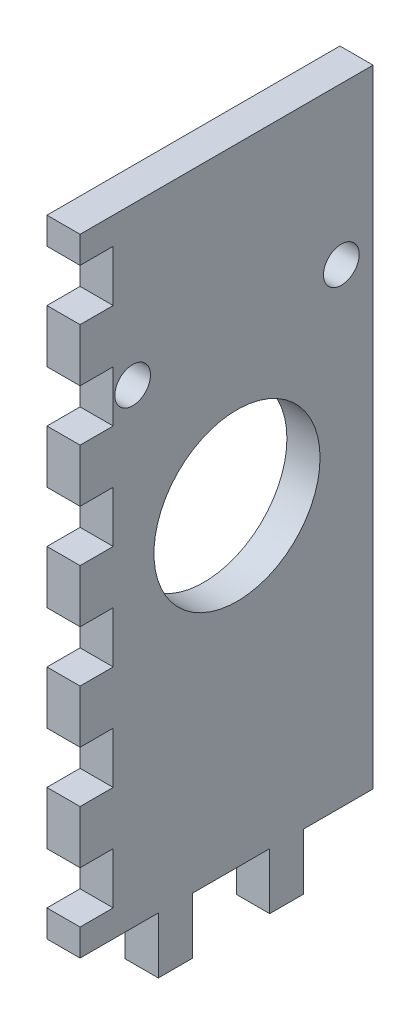
from build123d import *

# Parameters (mm, degrees)
SKETCH1_W           = 24.825
SKETCH1_H           = 3.175
SKETCH1_W_2         = 3.175
SKETCH1_H_2         = 24.825
BOSS_EXTRUDE1_DEPTH = 60
SKETCH2_W           = 3.125
SKETCH2_H           = 5.4
BOSS_EXTRUDE4_DEPTH = 3.175
SKETCH4_R           = 8
CUT_EXTRUDE1_DEPTH  = 3.175
SKETCH3_R           = 8
CUT_EXTRUDE2_DEPTH  = 3.175
SKETCH5_W           = 3.175
SKETCH5_H           = 5.4
BOSS_EXTRUDE5_DEPTH = 3.175
SKETCH6_R           = 1.75
CUT_EXTRUDE3_DEPTH  = 10
SKETCH7_R           = 1.75
CUT_EXTRUDE4_DEPTH  = 10
SKETCH9_W           = 3.175
SKETCH9_H           = 65.4
CUT_EXTRUDE5_DEPTH  = 24.825
SKETCH10_W          = 3.175
SKETCH10_H          = 5
CUT_EXTRUDE6_DEPTH  = 10
SKETCH11_R          = 7.95936
SKETCH11_R_2        = 1.70936
BOSS_EXTRUDE6_DEPTH = 3.175


with BuildPart() as part:
    # Sketch1 → Boss-Extrude1 (new body)
    with BuildSketch(Plane(origin=(0, 0, 0), x_dir=(1, 0, 0), z_dir=(0, 1, 0))):
        with Locations((-38.0875, 24.0875)):
            Rectangle(SKETCH1_W, SKETCH1_H)
        with Locations((-24.0875, 24.0875)):
            Rectangle(SKETCH1_W_2, SKETCH1_H)
        with Locations((-24.0875, 38.0875)):
            Rectangle(SKETCH1_W_2, SKETCH1_H_2)
    extrude(amount=BOSS_EXTRUDE1_DEPTH)

    # Sketch2 → Boss-Extrude4 (add)
    with BuildSketch(Plane.XY.offset(-22.5)):
        with Locations((-42.1875, -2.7)):
            Rectangle(SKETCH2_W, SKETCH2_H)
        with Locations((-31.5625, -2.7)):
            Rectangle(SKETCH2_W, SKETCH2_H)
    extrude(amount=-BOSS_EXTRUDE4_DEPTH)

    # Sketch4 → Cut-Extrude1 (cut)
    with BuildSketch(Plane.XY.offset(-22.5)):
        with Locations((-37.5, 30)):
            Circle(SKETCH4_R)
    extrude(amount=-CUT_EXTRUDE1_DEPTH, mode=Mode.SUBTRACT)

    # Sketch3 → Cut-Extrude2 (cut)
    with BuildSketch(Plane(origin=(-22.5, 0, 0), x_dir=(0, 0, -1), z_dir=(1, 0, 0))):
        with Locations((37.5, 30)):
            Circle(SKETCH3_R)
    extrude(amount=-CUT_EXTRUDE2_DEPTH, mode=Mode.SUBTRACT)

    # Sketch5 → Boss-Extrude5 (add)
    with BuildSketch(Plane(origin=(-22.5, 0, 0), x_dir=(0, 0, -1), z_dir=(1, 0, 0))):
        with Locations((42.2625, -2.7)):
            Rectangle(SKETCH5_W, SKETCH5_H)
        with Locations((31.5875, -2.7)):
            Rectangle(SKETCH5_W, SKETCH5_H)
    extrude(amount=-BOSS_EXTRUDE5_DEPTH)

    # Sketch6 → Cut-Extrude3 (cut)
    with BuildSketch(Plane.XY.offset(-22.5)):
        with Locations((-47.5, 45)):
            Circle(SKETCH6_R)
        with Locations((-27.5, 45)):
            Circle(SKETCH6_R)
    extrude(amount=-CUT_EXTRUDE3_DEPTH, mode=Mode.SUBTRACT)

    # Sketch7 → Cut-Extrude4 (cut)
    with BuildSketch(Plane(origin=(-22.5, 0, 0), x_dir=(0, 0, -1), z_dir=(1, 0, 0))):
        with Locations((47.5, 45)):
            Circle(SKETCH7_R)
        with Locations((27.5, 45)):
            Circle(SKETCH7_R)
    extrude(amount=-CUT_EXTRUDE4_DEPTH, mode=Mode.SUBTRACT)

    # Sketch9 → Cut-Extrude5 (cut)
    with BuildSketch(Plane.ZY.offset(50.5)):
        with Locations((-24.0875, 27.3)):
            Rectangle(SKETCH9_W, SKETCH9_H)
    extrude(amount=-CUT_EXTRUDE5_DEPTH, mode=Mode.SUBTRACT)

    # Sketch10 → Cut-Extrude6 (cut)
    with BuildSketch(Plane.ZY.offset(25.675)):
        with Locations((-24.0875, 55)):
            Rectangle(SKETCH10_W, SKETCH10_H)
        with Locations((-24.0875, 45)):
            Rectangle(SKETCH10_W, SKETCH10_H)
        with Locations((-24.0875, 35)):
            Rectangle(SKETCH10_W, SKETCH10_H)
        with Locations((-24.0875, 25)):
            Rectangle(SKETCH10_W, SKETCH10_H)
        with Locations((-24.0875, 15)):
            Rectangle(SKETCH10_W, SKETCH10_H)
        with Locations((-24.0875, 5)):
            Rectangle(SKETCH10_W, SKETCH10_H)
    extrude(amount=-CUT_EXTRUDE6_DEPTH, mode=Mode.SUBTRACT)

    # Sketch11 → Boss-Extrude6 (add)
    with BuildSketch(Plane(origin=(-22.5, 0, 0), x_dir=(0, 0, -1), z_dir=(1, 0, 0))):
        Polygon((25.63436, 57.45936), (25.63436, 52.54064), (22.45936, 52.54064), (22.45936, 47.45936), (25.63436, 47.45936), (25.63436, 42.54064), (22.45936, 42.54064), (22.45936, 37.45936), (25.63436, 37.45936), (25.63436, 32.54064), (22.45936, 32.54064), (22.45936, 27.45936), (25.63436, 27.45936), (25.63436, 22.54064), (22.45936, 22.54064), (22.45936, 17.45936), (25.63436, 17.45936), (25.63436, 12.54064), (22.45936, 12.54064), (22.45936, 7.45936), (25.63436, 7.45936), (25.63436, 2.54064), (22.45936, 2.54064), (22.45936, -0.04064), (29.95936, -0.04064), (29.95936, -5.44064), (33.21564, -5.44064), (33.21564, -0.04064), (40.63436, -0.04064), (40.63436, -5.44064), (43.89064, -5.44064), (43.89064, -0.04064), (50.54064, -0.04064), (50.54064, 60.04064), (22.45936, 60.04064), (22.45936, 57.45936), align=None)
        with Locations((37.5, 30)):
            Circle(SKETCH11_R, mode=Mode.SUBTRACT)
        with Locations((27.5, 45)):
            Circle(SKETCH11_R_2, mode=Mode.SUBTRACT)
        with Locations((47.5, 45)):
            Circle(SKETCH11_R_2, mode=Mode.SUBTRACT)
    extrude(amount=-BOSS_EXTRUDE6_DEPTH)


solid = part.part
